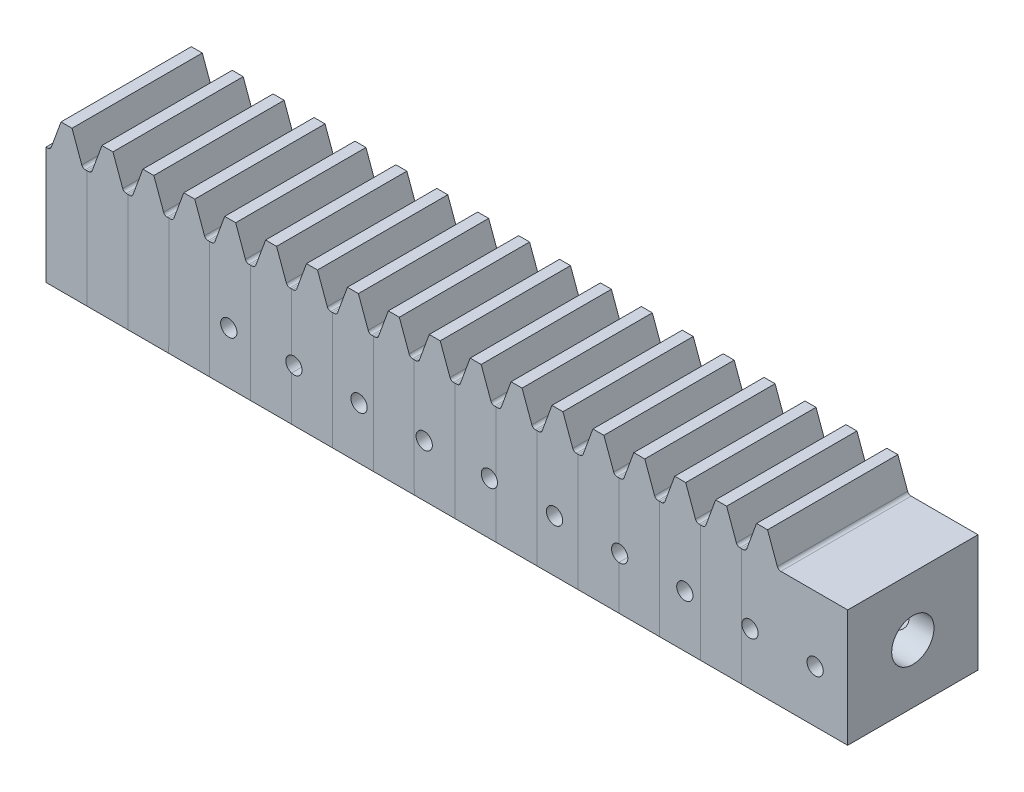
from build123d import *

# Parameters (mm, degrees)
MAIN_DEPTH          = 20
SKETCH2_W           = 6.295443825
SKETCH2_H           = 18
SUPPORT_DEPTH       = 20
FILLET1_R           = 0.57
LPATTERN2_COUNT     = 18
LPATTERN2_PITCH     = 6.28
SKETCH3_R           = 6.15
AXISHOLE_DEPTH      = 93.388443825
SKETCH4_W           = 20
SKETCH4_H           = 18
BOSS_EXTRUDE1_DEPTH = 10
SKETCH5_R           = 1.25
CUT_EXTRUDE1_DEPTH  = 21
LPATTERN3_COUNT     = 10
LPATTERN3_PITCH     = 10
SKETCH6_R           = 3.25
CUT_EXTRUDE2_DEPTH  = 31.667


with BuildPart() as part:
    # Sketch1 → Main (new body)
    with BuildSketch(Plane.XY):
        Polygon((-4.961443825, 0), (-3.323577771, 4.5), (-1.637866054, 4.5), (0, 0), align=None)
    extrude(amount=MAIN_DEPTH)

    # Sketch2 → Support (add)
    with BuildSketch(Plane.XY.offset(20)):
        with Locations((-2.480721913, -9)):
            Rectangle(SKETCH2_W, SKETCH2_H)
    extrude(amount=-SUPPORT_DEPTH)

    # Fillet1
    fillet1_edges = [part.edges().sort_by_distance(p)[0] for p in [
        (-4.961443825, 0, 10),
        (0, 0, 10),
    ]]
    fillet(fillet1_edges, radius=FILLET1_R)


with BuildPart() as lpattern2_1:
    # LPattern2: pattern copy
    add(part.part.moved(Location(Vector(-1, 0, 0) * (1 * LPATTERN2_PITCH))))


with BuildPart() as lpattern2_2:
    # LPattern2: pattern copy
    add(part.part.moved(Location(Vector(-1, 0, 0) * (2 * LPATTERN2_PITCH))))


with BuildPart() as lpattern2_3:
    # LPattern2: pattern copy
    add(part.part.moved(Location(Vector(-1, 0, 0) * (3 * LPATTERN2_PITCH))))


with BuildPart() as lpattern2_4:
    # LPattern2: pattern copy
    add(part.part.moved(Location(Vector(-1, 0, 0) * (4 * LPATTERN2_PITCH))))


with BuildPart() as lpattern2_5:
    # LPattern2: pattern copy
    add(part.part.moved(Location(Vector(-1, 0, 0) * (5 * LPATTERN2_PITCH))))


with BuildPart() as lpattern2_6:
    # LPattern2: pattern copy
    add(part.part.moved(Location(Vector(-1, 0, 0) * (6 * LPATTERN2_PITCH))))


with BuildPart() as lpattern2_7:
    # LPattern2: pattern copy
    add(part.part.moved(Location(Vector(-1, 0, 0) * (7 * LPATTERN2_PITCH))))


with BuildPart() as lpattern2_8:
    # LPattern2: pattern copy
    add(part.part.moved(Location(Vector(-1, 0, 0) * (8 * LPATTERN2_PITCH))))


with BuildPart() as lpattern2_9:
    # LPattern2: pattern copy
    add(part.part.moved(Location(Vector(-1, 0, 0) * (9 * LPATTERN2_PITCH))))


with BuildPart() as lpattern2_10:
    # LPattern2: pattern copy
    add(part.part.moved(Location(Vector(-1, 0, 0) * (10 * LPATTERN2_PITCH))))


with BuildPart() as lpattern2_11:
    # LPattern2: pattern copy
    add(part.part.moved(Location(Vector(-1, 0, 0) * (11 * LPATTERN2_PITCH))))


with BuildPart() as lpattern2_12:
    # LPattern2: pattern copy
    add(part.part.moved(Location(Vector(-1, 0, 0) * (12 * LPATTERN2_PITCH))))


with BuildPart() as lpattern2_13:
    # LPattern2: pattern copy
    add(part.part.moved(Location(Vector(-1, 0, 0) * (13 * LPATTERN2_PITCH))))


with BuildPart() as lpattern2_14:
    # LPattern2: pattern copy
    add(part.part.moved(Location(Vector(-1, 0, 0) * (14 * LPATTERN2_PITCH))))


with BuildPart() as lpattern2_15:
    # LPattern2: pattern copy
    add(part.part.moved(Location(Vector(-1, 0, 0) * (15 * LPATTERN2_PITCH))))


with BuildPart() as lpattern2_16:
    # LPattern2: pattern copy
    add(part.part.moved(Location(Vector(-1, 0, 0) * (16 * LPATTERN2_PITCH))))


with BuildPart() as lpattern2_17:
    # LPattern2: pattern copy
    add(part.part.moved(Location(Vector(-1, 0, 0) * (17 * LPATTERN2_PITCH))))


with BuildPart() as axishole_tool:
    # Sketch3 → AxisHole (new body, through all)
    with BuildSketch(Plane.ZY.offset(20)):
        with Locations((10, -9)):
            Circle(SKETCH3_R)
    extrude(amount=AXISHOLE_DEPTH)


with BuildPart() as lpattern2_3_1:
    add(lpattern2_3.part)

    # AxisHole: cut by axishole_tool
    add(axishole_tool.part, mode=Mode.SUBTRACT)


with BuildPart() as lpattern2_4_1:
    add(lpattern2_4.part)

    # AxisHole: cut by axishole_tool
    add(axishole_tool.part, mode=Mode.SUBTRACT)


with BuildPart() as lpattern2_5_1:
    add(lpattern2_5.part)

    # AxisHole: cut by axishole_tool
    add(axishole_tool.part, mode=Mode.SUBTRACT)


with BuildPart() as lpattern2_6_1:
    add(lpattern2_6.part)

    # AxisHole: cut by axishole_tool
    add(axishole_tool.part, mode=Mode.SUBTRACT)


with BuildPart() as lpattern2_7_1:
    add(lpattern2_7.part)

    # AxisHole: cut by axishole_tool
    add(axishole_tool.part, mode=Mode.SUBTRACT)


with BuildPart() as lpattern2_8_1:
    add(lpattern2_8.part)

    # AxisHole: cut by axishole_tool
    add(axishole_tool.part, mode=Mode.SUBTRACT)


with BuildPart() as lpattern2_9_1:
    add(lpattern2_9.part)

    # AxisHole: cut by axishole_tool
    add(axishole_tool.part, mode=Mode.SUBTRACT)


with BuildPart() as lpattern2_10_1:
    add(lpattern2_10.part)

    # AxisHole: cut by axishole_tool
    add(axishole_tool.part, mode=Mode.SUBTRACT)


with BuildPart() as lpattern2_11_1:
    add(lpattern2_11.part)

    # AxisHole: cut by axishole_tool
    add(axishole_tool.part, mode=Mode.SUBTRACT)


with BuildPart() as lpattern2_12_1:
    add(lpattern2_12.part)

    # AxisHole: cut by axishole_tool
    add(axishole_tool.part, mode=Mode.SUBTRACT)


with BuildPart() as lpattern2_13_1:
    add(lpattern2_13.part)

    # AxisHole: cut by axishole_tool
    add(axishole_tool.part, mode=Mode.SUBTRACT)


with BuildPart() as lpattern2_14_1:
    add(lpattern2_14.part)

    # AxisHole: cut by axishole_tool
    add(axishole_tool.part, mode=Mode.SUBTRACT)


with BuildPart() as lpattern2_15_1:
    add(lpattern2_15.part)

    # AxisHole: cut by axishole_tool
    add(axishole_tool.part, mode=Mode.SUBTRACT)


with BuildPart() as lpattern2_16_1:
    add(lpattern2_16.part)

    # AxisHole: cut by axishole_tool
    add(axishole_tool.part, mode=Mode.SUBTRACT)


with BuildPart() as lpattern2_17_1:
    add(lpattern2_17.part)

    # AxisHole: cut by axishole_tool
    add(axishole_tool.part, mode=Mode.SUBTRACT)


with BuildPart() as part_1:
    add(part.part)

    # Sketch4 → Boss-Extrude1 (add)
    with BuildSketch(Plane(origin=(0.667, 0, 0), x_dir=(0, 0, -1), z_dir=(1, 0, 0))):
        with Locations((-10, -9)):
            Rectangle(SKETCH4_W, SKETCH4_H)
    extrude(amount=BOSS_EXTRUDE1_DEPTH)

    # Sketch5 → Cut-Extrude1 (cut, through all)
    with BuildSketch(Plane.XY.offset(20)):
        with Locations((5.667, -10)):
            Circle(SKETCH5_R)
    cut_extrude1 = extrude(amount=-CUT_EXTRUDE1_DEPTH, mode=Mode.SUBTRACT)


with BuildPart() as lpattern3_tool:
    # LPattern3: Cut-Extrude1 ×10
    with Locations(*[(-i * LPATTERN3_PITCH, 0, 0) for i in range(1, LPATTERN3_COUNT)]):
        add(cut_extrude1)


with BuildPart() as part_2:
    add(part_1.part)

    # LPattern3: cut by lpattern3_tool
    add(lpattern3_tool.part, mode=Mode.SUBTRACT)


with BuildPart() as lpattern2_2_1:
    add(lpattern2_2.part)

    # LPattern3: cut by lpattern3_tool
    add(lpattern3_tool.part, mode=Mode.SUBTRACT)


with BuildPart() as lpattern2_3_2:
    add(lpattern2_3_1.part)

    # LPattern3: cut by lpattern3_tool
    add(lpattern3_tool.part, mode=Mode.SUBTRACT)


with BuildPart() as lpattern2_4_2:
    add(lpattern2_4_1.part)

    # LPattern3: cut by lpattern3_tool
    add(lpattern3_tool.part, mode=Mode.SUBTRACT)


with BuildPart() as lpattern2_5_2:
    add(lpattern2_5_1.part)

    # LPattern3: cut by lpattern3_tool
    add(lpattern3_tool.part, mode=Mode.SUBTRACT)


with BuildPart() as lpattern2_6_2:
    add(lpattern2_6_1.part)

    # LPattern3: cut by lpattern3_tool
    add(lpattern3_tool.part, mode=Mode.SUBTRACT)


with BuildPart() as lpattern2_7_2:
    add(lpattern2_7_1.part)

    # LPattern3: cut by lpattern3_tool
    add(lpattern3_tool.part, mode=Mode.SUBTRACT)


with BuildPart() as lpattern2_8_2:
    add(lpattern2_8_1.part)

    # LPattern3: cut by lpattern3_tool
    add(lpattern3_tool.part, mode=Mode.SUBTRACT)


with BuildPart() as lpattern2_10_2:
    add(lpattern2_10_1.part)

    # LPattern3: cut by lpattern3_tool
    add(lpattern3_tool.part, mode=Mode.SUBTRACT)


with BuildPart() as lpattern2_11_2:
    add(lpattern2_11_1.part)

    # LPattern3: cut by lpattern3_tool
    add(lpattern3_tool.part, mode=Mode.SUBTRACT)


with BuildPart() as lpattern2_12_2:
    add(lpattern2_12_1.part)

    # LPattern3: cut by lpattern3_tool
    add(lpattern3_tool.part, mode=Mode.SUBTRACT)


with BuildPart() as lpattern2_13_2:
    add(lpattern2_13_1.part)

    # LPattern3: cut by lpattern3_tool
    add(lpattern3_tool.part, mode=Mode.SUBTRACT)


with BuildPart() as cut_extrude2_tool:
    # Sketch6 → Cut-Extrude2 (new body, through all)
    with BuildSketch(Plane.ZY.offset(20)):
        with Locations((10, -9)):
            Circle(SKETCH6_R)
    extrude(amount=-CUT_EXTRUDE2_DEPTH)


with BuildPart() as part_3:
    add(part_2.part)

    # Cut-Extrude2: cut by cut_extrude2_tool
    add(cut_extrude2_tool.part, mode=Mode.SUBTRACT)


with BuildPart() as lpattern2_1_1:
    add(lpattern2_1.part)

    # Cut-Extrude2: cut by cut_extrude2_tool
    add(cut_extrude2_tool.part, mode=Mode.SUBTRACT)


with BuildPart() as lpattern2_2_2:
    add(lpattern2_2_1.part)

    # Cut-Extrude2: cut by cut_extrude2_tool
    add(cut_extrude2_tool.part, mode=Mode.SUBTRACT)


with BuildPart() as lpattern2_3_3:
    add(lpattern2_3_2.part)

    # Cut-Extrude2: cut by cut_extrude2_tool
    add(cut_extrude2_tool.part, mode=Mode.SUBTRACT)


solid = Compound([lpattern2_9_1.part, lpattern2_14_1.part, lpattern2_15_1.part, lpattern2_16_1.part, lpattern2_17_1.part, lpattern2_4_2.part, lpattern2_5_2.part, lpattern2_6_2.part, lpattern2_7_2.part, lpattern2_8_2.part, lpattern2_10_2.part, lpattern2_11_2.part, lpattern2_12_2.part, lpattern2_13_2.part, part_3.part, lpattern2_1_1.part, lpattern2_2_2.part, lpattern2_3_3.part])
